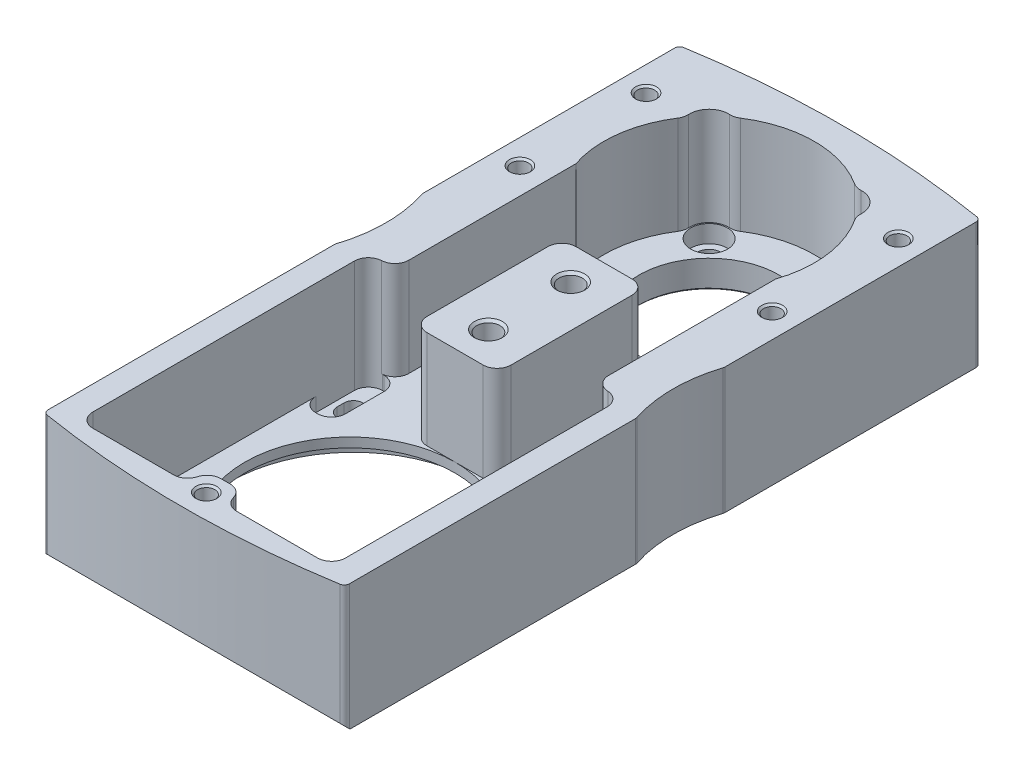
from build123d import *
from build123d.topology import SkipClean

# Parameters (mm, degrees)
BOSS_EXTRUDE1_DEPTH     = 36
CUT_EXTRUDE1_DEPTH      = 43
CUT_EXTRUDE1_DEPTH_BACK = 43
CUT_EXTRUDE2_DEPTH      = 32
CUT_EXTRUDE3_DEPTH      = 32
CUT_EXTRUDE4_DEPTH      = 32
CUT_EXTRUDE5_DEPTH      = 32
CUT_EXTRUDE6_DEPTH      = 36
CUT_EXTRUDE7_DEPTH      = 36
CUT_EXTRUDE8_DEPTH      = 36
CUT_EXTRUDE9_DEPTH      = 36
CUT_EXTRUDE10_DEPTH     = 5.3
CUT_EXTRUDE11_DEPTH     = 28
SKETCH25_W              = 30
SKETCH25_H              = 20
CUT_EXTRUDE12_DEPTH     = 28


with BuildPart() as part:
    # Sketch1 → Boss-Extrude1 (new body)
    with BuildSketch(Plane(origin=(0, 0, 0), x_dir=(1, 0, 0), z_dir=(0, 1, 0))):
        with BuildLine():
            Line((-43, 86.522077939), (-43, 4.879475348))
            ThreePointArc((-43, 4.879475348), (-42.64324868, 3.90840251), (-41.742690058, 3.399238362))
            ThreePointArc((-41.742690058, 3.399238362), (0, 0), (41.742690058, 3.399238362))
            ThreePointArc((41.742690058, 3.399238362), (42.64324868, 3.90840251), (43, 4.879475348))
            Line((43, 4.879475348), (43, 86.522077939))
            ThreePointArc((43, 86.522077939), (42.98181751, 86.754923096), (42.927710843, 86.982123314))
            ThreePointArc((42.927710843, 86.982123314), (41, 99.25), (42.927710843, 111.517876686))
            ThreePointArc((42.927710843, 111.517876686), (42.98181751, 111.745076904), (43, 111.977922061))
            Line((43, 111.977922061), (43, 183.620524652))
            ThreePointArc((43, 183.620524652), (42.64324868, 184.59159749), (41.742690058, 185.100761638))
            ThreePointArc((41.742690058, 185.100761638), (0, 188.5), (-41.742690058, 185.100761638))
            ThreePointArc((-41.742690058, 185.100761638), (-42.64324868, 184.59159749), (-43, 183.620524652))
            Line((-43, 183.620524652), (-43, 111.977922061))
            ThreePointArc((-43, 111.977922061), (-42.98181751, 111.745076904), (-42.927710843, 111.517876686))
            ThreePointArc((-42.927710843, 111.517876686), (-41, 99.25), (-42.927710843, 86.982123314))
            ThreePointArc((-42.927710843, 86.982123314), (-42.98181751, 86.754923096), (-43, 86.522077939))
        make_face()
    extrude(amount=BOSS_EXTRUDE1_DEPTH)

    # Sketch2 → Cut-Extrude1 (cut, two sides: drawn at the far end of the back side and taken through both)
    with BuildSketch(Plane(origin=(0, 0, 0), x_dir=(0, 0, -1), z_dir=(1, 0, 0)).offset(-CUT_EXTRUDE1_DEPTH_BACK)):
        Polygon((0, 5), (0, 0), (5, 0), align=None)
    extrude(amount=CUT_EXTRUDE1_DEPTH + CUT_EXTRUDE1_DEPTH_BACK, mode=Mode.SUBTRACT)

    # Sketch4 → Cut-Revolve1 (revolve, cut)
    with BuildSketch(Plane(origin=(0, 0, 0), x_dir=(0, 0, -1), z_dir=(1, 0, 0))):
        Polygon((111, 36), (115, 36), (114.3235, 35.3235), (114.3235, 6), (111, 4.08117638), align=None)
    revolve(axis=Axis((0, 4.08117638, -111), (0, 1, 0)), mode=Mode.SUBTRACT)

    # Sketch5 → Cut-Revolve2 (revolve, cut)
    with BuildSketch(Plane(origin=(0, 0, 0), x_dir=(0, 0, -1), z_dir=(1, 0, 0))):
        Polygon((87.5, 36), (91.5, 36), (90.8235, 35.3235), (90.8235, 6), (87.5, 4.08117638), align=None)
    revolve(axis=Axis((0, 4.08117638, -87.5), (0, 1, 0)), mode=Mode.SUBTRACT)

    # Sketch6 → Cut-Revolve3 (revolve, cut)
    with BuildSketch(Plane(origin=(-36, 0, 0), x_dir=(0, 0, -1), z_dir=(1, 0, 0))):
        Polygon((168.5, 36), (171.5, 36), (170.9585, 35.4585), (170.9585, 14), (168.5, 12.580584363), align=None)
    revolve(axis=Axis((-36, 12.580584363, -168.5), (0, 1, 0)), mode=Mode.SUBTRACT)

    # Sketch7 → Cut-Revolve4 (revolve, cut)
    with BuildSketch(Plane(origin=(-36, 0, 0), x_dir=(0, 0, -1), z_dir=(1, 0, 0))):
        Polygon((132.5, 36), (135.5, 36), (134.9585, 35.4585), (134.9585, 14), (132.5, 12.580584363), align=None)
    revolve(axis=Axis((-36, 12.580584363, -132.5), (0, 1, 0)), mode=Mode.SUBTRACT)

    # Sketch8 → Cut-Revolve5 (revolve, cut)
    with BuildSketch(Plane(origin=(36, 0, 0), x_dir=(0, 0, -1), z_dir=(1, 0, 0))):
        Polygon((168.5, 36), (171.5, 36), (170.9585, 35.4585), (170.9585, 14), (168.5, 12.580584363), align=None)
    revolve(axis=Axis((36, 12.580584363, -168.5), (0, 1, 0)), mode=Mode.SUBTRACT)

    # Sketch9 → Cut-Revolve6 (revolve, cut)
    with BuildSketch(Plane(origin=(36, 0, 0), x_dir=(0, 0, -1), z_dir=(1, 0, 0))):
        Polygon((132.5, 36), (135.5, 36), (134.9585, 35.4585), (134.9585, 14), (132.5, 12.580584363), align=None)
    revolve(axis=Axis((36, 12.580584363, -132.5), (0, 1, 0)), mode=Mode.SUBTRACT)

    # Sketch10 → Cut-Revolve7 (revolve, cut)
    with BuildSketch(Plane(origin=(0, 0, 0), x_dir=(0, 0, -1), z_dir=(1, 0, 0))):
        Polygon((7, 36), (10, 36), (9.4585, 35.4585), (9.4585, 14), (7, 12.580584363), align=None)
    revolve(axis=Axis((0, 12.580584363, -7), (0, 1, 0)), mode=Mode.SUBTRACT)

    # Sketch11 → Cut-Revolve8 (revolve, cut)
    with BuildSketch(Plane(origin=(0, 0, 0), x_dir=(0, 0, -1), z_dir=(1, 0, 0))):
        Polygon((150.5, 36), (170.5, 36), (170.5, 0.6), (171.1, 0), (150.5, 0), align=None)
    revolve(axis=Axis((0, 0, -150.5), (0, 1, 0)), mode=Mode.SUBTRACT)

    # Sketch12 → Cut-Revolve9 (revolve, cut)
    with BuildSketch(Plane(origin=(19, 0, 0), x_dir=(0, 0, -1), z_dir=(1, 0, 0))):
        Polygon((131.5, 36), (136.75, 36), (136.75, 3), (134.8, 3), (134.8, 0), (131.5, 0), align=None)
    revolve(axis=Axis((19, 0, -131.5), (0, 1, 0)), mode=Mode.SUBTRACT)

    # Sketch13 → Cut-Revolve10 (revolve, cut)
    with BuildSketch(Plane(origin=(19, 0, 0), x_dir=(0, 0, -1), z_dir=(1, 0, 0))):
        Polygon((169.5, 36), (174.75, 36), (174.75, 3), (172.8, 3), (172.8, 0), (169.5, 0), align=None)
    revolve(axis=Axis((19, 0, -169.5), (0, 1, 0)), mode=Mode.SUBTRACT)

    # Sketch14 → Cut-Revolve11 (revolve, cut)
    with BuildSketch(Plane(origin=(-19, 0, 0), x_dir=(0, 0, -1), z_dir=(1, 0, 0))):
        Polygon((131.5, 36), (136.75, 36), (136.75, 3), (134.8, 3), (134.8, 0), (131.5, 0), align=None)
    revolve(axis=Axis((-19, 0, -131.5), (0, 1, 0)), mode=Mode.SUBTRACT)

    # Sketch15 → Cut-Revolve12 (revolve, cut)
    with BuildSketch(Plane(origin=(-19, 0, 0), x_dir=(0, 0, -1), z_dir=(1, 0, 0))):
        Polygon((169.5, 36), (174.75, 36), (174.75, 3), (172.8, 3), (172.8, 0), (169.5, 0), align=None)
    revolve(axis=Axis((-19, 0, -169.5), (0, 1, 0)), mode=Mode.SUBTRACT)

    # Sketch16 → Cut-Extrude2 (cut)
    with BuildSketch(Plane(origin=(0, 36, 0), x_dir=(1, 0, 0), z_dir=(0, 1, 0))):
        with BuildLine():
            Line((31.569805153, 6.680194847), (32.069805153, 6.680194847))
            ThreePointArc((32.069805153, 6.680194847), (34.898232278, 7.851767722), (36.069805153, 10.680194847))
            Line((36.069805153, 10.680194847), (36.069805153, 21.680194847))
            ThreePointArc((36.069805153, 21.680194847), (34.898232278, 24.508621971), (32.069805153, 25.680194847))
            Line((32.069805153, 25.680194847), (31.569805153, 25.680194847))
            ThreePointArc((31.569805153, 25.680194847), (28.741378029, 24.508621971), (27.569805153, 21.680194847))
            Line((27.569805153, 21.680194847), (27.569805153, 10.680194847))
            ThreePointArc((27.569805153, 10.680194847), (28.741378029, 7.851767722), (31.569805153, 6.680194847))
        make_face()
    extrude(amount=-CUT_EXTRUDE2_DEPTH, mode=Mode.SUBTRACT)

    # Sketch17 → Cut-Extrude3 (cut)
    with BuildSketch(Plane(origin=(0, 36, 0), x_dir=(1, 0, 0), z_dir=(0, 1, 0))):
        with BuildLine():
            Line((31.569805153, 70.319805153), (32.069805153, 70.319805153))
            ThreePointArc((32.069805153, 70.319805153), (34.898232278, 71.491378029), (36.069805153, 74.319805153))
            Line((36.069805153, 74.319805153), (36.069805153, 85.319805153))
            ThreePointArc((36.069805153, 85.319805153), (34.898232278, 88.148232278), (32.069805153, 89.319805153))
            Line((32.069805153, 89.319805153), (31.569805153, 89.319805153))
            ThreePointArc((31.569805153, 89.319805153), (28.741378029, 88.148232278), (27.569805153, 85.319805153))
            Line((27.569805153, 85.319805153), (27.569805153, 74.319805153))
            ThreePointArc((27.569805153, 74.319805153), (28.741378029, 71.491378029), (31.569805153, 70.319805153))
        make_face()
    extrude(amount=-CUT_EXTRUDE3_DEPTH, mode=Mode.SUBTRACT)

    # Sketch18 → Cut-Extrude4 (cut)
    with BuildSketch(Plane(origin=(0, 36, 0), x_dir=(1, 0, 0), z_dir=(0, 1, 0))):
        with BuildLine():
            Line((-32.069805153, 70.319805153), (-31.569805153, 70.319805153))
            ThreePointArc((-31.569805153, 70.319805153), (-28.741378029, 71.491378029), (-27.569805153, 74.319805153))
            Line((-27.569805153, 74.319805153), (-27.569805153, 85.319805153))
            ThreePointArc((-27.569805153, 85.319805153), (-28.741378029, 88.148232278), (-31.569805153, 89.319805153))
            Line((-31.569805153, 89.319805153), (-32.069805153, 89.319805153))
            ThreePointArc((-32.069805153, 89.319805153), (-34.898232278, 88.148232278), (-36.069805153, 85.319805153))
            Line((-36.069805153, 85.319805153), (-36.069805153, 74.319805153))
            ThreePointArc((-36.069805153, 74.319805153), (-34.898232278, 71.491378029), (-32.069805153, 70.319805153))
        make_face()
    extrude(amount=-CUT_EXTRUDE4_DEPTH, mode=Mode.SUBTRACT)

    # Sketch19 → Cut-Extrude5 (cut)
    with BuildSketch(Plane(origin=(0, 36, 0), x_dir=(1, 0, 0), z_dir=(0, 1, 0))):
        with BuildLine():
            Line((-32.069805153, 6.680194847), (-31.569805153, 6.680194847))
            ThreePointArc((-31.569805153, 6.680194847), (-28.741378029, 7.851767722), (-27.569805153, 10.680194847))
            Line((-27.569805153, 10.680194847), (-27.569805153, 21.680194847))
            ThreePointArc((-27.569805153, 21.680194847), (-28.741378029, 24.508621971), (-31.569805153, 25.680194847))
            Line((-31.569805153, 25.680194847), (-32.069805153, 25.680194847))
            ThreePointArc((-32.069805153, 25.680194847), (-34.898232278, 24.508621971), (-36.069805153, 21.680194847))
            Line((-36.069805153, 21.680194847), (-36.069805153, 10.680194847))
            ThreePointArc((-36.069805153, 10.680194847), (-34.898232278, 7.851767722), (-32.069805153, 6.680194847))
        make_face()
    extrude(amount=-CUT_EXTRUDE5_DEPTH, mode=Mode.SUBTRACT)

    # Sketch20 → Cut-Extrude6 (cut)
    with BuildSketch(Plane(origin=(0, 36, 0), x_dir=(1, 0, 0), z_dir=(0, 1, 0))):
        with BuildLine():
            Line((34.469805153, 15.180194847), (34.469805153, 17.180194847))
            ThreePointArc((34.469805153, 17.180194847), (31.819805153, 19.830194847), (29.169805153, 17.180194847))
            Line((29.169805153, 17.180194847), (29.169805153, 15.180194847))
            ThreePointArc((29.169805153, 15.180194847), (31.819805153, 12.530194847), (34.469805153, 15.180194847))
        make_face()
    extrude(amount=-CUT_EXTRUDE6_DEPTH, mode=Mode.SUBTRACT)

    # Sketch21 → Cut-Extrude7 (cut)
    with BuildSketch(Plane(origin=(0, 36, 0), x_dir=(1, 0, 0), z_dir=(0, 1, 0))):
        with BuildLine():
            Line((34.469805153, 78.819805153), (34.469805153, 80.819805153))
            ThreePointArc((34.469805153, 80.819805153), (31.819805153, 83.469805153), (29.169805153, 80.819805153))
            Line((29.169805153, 80.819805153), (29.169805153, 78.819805153))
            ThreePointArc((29.169805153, 78.819805153), (31.819805153, 76.169805153), (34.469805153, 78.819805153))
        make_face()
    extrude(amount=-CUT_EXTRUDE7_DEPTH, mode=Mode.SUBTRACT)

    # Sketch22 → Cut-Extrude8 (cut)
    with BuildSketch(Plane(origin=(0, 36, 0), x_dir=(1, 0, 0), z_dir=(0, 1, 0))):
        with BuildLine():
            Line((-29.169805153, 78.819805153), (-29.169805153, 80.819805153))
            ThreePointArc((-29.169805153, 80.819805153), (-31.819805153, 83.469805153), (-34.469805153, 80.819805153))
            Line((-34.469805153, 80.819805153), (-34.469805153, 78.819805153))
            ThreePointArc((-34.469805153, 78.819805153), (-31.819805153, 76.169805153), (-29.169805153, 78.819805153))
        make_face()
    extrude(amount=-CUT_EXTRUDE8_DEPTH, mode=Mode.SUBTRACT)

    # Sketch23 → Cut-Extrude9 (cut)
    with BuildSketch(Plane(origin=(0, 36, 0), x_dir=(1, 0, 0), z_dir=(0, 1, 0))):
        with BuildLine():
            Line((-29.169805153, 15.180194847), (-29.169805153, 17.180194847))
            ThreePointArc((-29.169805153, 17.180194847), (-31.819805153, 19.830194847), (-34.469805153, 17.180194847))
            Line((-34.469805153, 17.180194847), (-34.469805153, 15.180194847))
            ThreePointArc((-34.469805153, 15.180194847), (-31.819805153, 12.530194847), (-29.169805153, 15.180194847))
        make_face()
    extrude(amount=-CUT_EXTRUDE9_DEPTH, mode=Mode.SUBTRACT)

    # Sketch24 → Cut-Extrude10 (cut)
    with BuildSketch(Plane(origin=(0, 0, 0), x_dir=(1, 0, 0), z_dir=(0, 1, 0))):
        with BuildLine():
            Line((35.25, 47), (35.25, 49))
            ThreePointArc((35.25, 49), (0, 84.25), (-35.25, 49))
            Line((-35.25, 49), (-35.25, 47))
            ThreePointArc((-35.25, 47), (0, 11.75), (35.25, 47))
        make_face()
    extrude(amount=CUT_EXTRUDE10_DEPTH, mode=Mode.SUBTRACT)

    # Sketch3 → Cut-Extrude11 (cut)
    with BuildSketch(Plane(origin=(0, 36, 0), x_dir=(1, 0, 0), z_dir=(0, 1, 0))):
        with BuildLine():
            Line((28.5, 57.526410657), (28.5, 141.132503002))
            ThreePointArc((28.5, 141.132503002), (0, 180.5), (-28.5, 141.132503002))
            Line((-28.5, 141.132503002), (-28.5, 57.526410657))
            ThreePointArc((-28.5, 57.526410657), (0, 17.95), (28.5, 57.526410657))
        make_face()
        with BuildLine():
            Line((-12, 116.5), (-12, 82))
            ThreePointArc((-12, 82), (-10.828427125, 79.171572875), (-8, 78))
            Line((-8, 78), (8, 78))
            ThreePointArc((8, 78), (10.828427125, 79.171572875), (12, 82))
            Line((12, 82), (12, 116.5))
            ThreePointArc((12, 116.5), (10.828427125, 119.328427125), (8, 120.5))
            Line((8, 120.5), (-8, 120.5))
            ThreePointArc((-8, 120.5), (-10.828427125, 119.328427125), (-12, 116.5))
        make_face(mode=Mode.SUBTRACT)
    extrude(amount=-CUT_EXTRUDE11_DEPTH, mode=Mode.SUBTRACT)

    # Sketch25 → Cut-Revolve13 (revolve, cut)
    with BuildSketch(Plane(origin=(0, 0, 0), x_dir=(0, 0, -1), z_dir=(1, 0, 0))):
        with Locations((63, 10)):
            Rectangle(SKETCH25_W, SKETCH25_H)
    revolve(axis=Axis((0, 0, -48), (0, 1, 0)), mode=Mode.SUBTRACT)

    # Sketch26 → Cut-Extrude12 (cut)
    with SkipClean():  # the faces are left unmerged after this step: merging them gives an invalid solid
        with BuildSketch(Plane(origin=(0, 36, 0), x_dir=(1, 0, 0), z_dir=(0, 1, 0))):
            with BuildLine():
                Line((-36.069805153, 85.319805153), (-36.069805153, 10.680194847))
                ThreePointArc((-36.069805153, 10.680194847), (-34.898232278, 7.851767722), (-32.069805153, 6.680194847))
                Line((-32.069805153, 6.680194847), (-9, 6.680194847))
                ThreePointArc((-9, 6.680194847), (-6.587572767, 7.489553086), (-5.151404463, 9.590097423))
                ThreePointArc((-5.151404463, 9.590097423), (-3.715236159, 11.690641761), (-1.302808926, 12.5))
                Line((-1.302808926, 12.5), (1.302808926, 12.5))
                ThreePointArc((1.302808926, 12.5), (3.715236159, 11.690641761), (5.151404463, 9.590097423))
                ThreePointArc((5.151404463, 9.590097423), (6.587572767, 7.489553086), (9, 6.680194847))
                Line((9, 6.680194847), (32.069805153, 6.680194847))
                ThreePointArc((32.069805153, 6.680194847), (34.898232278, 7.851767722), (36.069805153, 10.680194847))
                Line((36.069805153, 10.680194847), (36.069805153, 85.319805153))
                ThreePointArc((36.069805153, 85.319805153), (34.973284936, 88.071133043), (32.284902577, 89.314017604))
                ThreePointArc((32.284902577, 89.314017604), (29.596520218, 90.556902165), (28.5, 93.308230054))
                Line((28.5, 93.308230054), (28.5, 140.973589343))
                ThreePointArc((28.5, 140.973589343), (29.812257553, 154.272505746), (25.228664015, 166.825348757))
                ThreePointArc((25.228664015, 166.825348757), (24.722390611, 167.9661352), (24.592351825, 169.207423395))
                ThreePointArc((24.592351825, 169.207423395), (22.959797975, 173.459797975), (18.707423395, 175.092351825))
                ThreePointArc((18.707423395, 175.092351825), (17.4661352, 175.222390611), (16.325348757, 175.728664015))
                ThreePointArc((16.325348757, 175.728664015), (0, 180.55), (-16.325348757, 175.728664015))
                ThreePointArc((-16.325348757, 175.728664015), (-17.4661352, 175.222390611), (-18.707423395, 175.092351825))
                ThreePointArc((-18.707423395, 175.092351825), (-22.959797975, 173.459797975), (-24.592351825, 169.207423395))
                ThreePointArc((-24.592351825, 169.207423395), (-24.722390611, 167.9661352), (-25.228664015, 166.825348757))
                ThreePointArc((-25.228664015, 166.825348757), (-29.812257553, 154.272505746), (-28.5, 140.973589343))
                Line((-28.5, 140.973589343), (-28.5, 93.308230054))
                ThreePointArc((-28.5, 93.308230054), (-29.596520218, 90.556902165), (-32.284902577, 89.314017604))
                ThreePointArc((-32.284902577, 89.314017604), (-34.973284936, 88.071133043), (-36.069805153, 85.319805153))
            make_face()
            with BuildLine():
                Line((-12, 116.5), (-12, 82))
                ThreePointArc((-12, 82), (-10.828427125, 79.171572875), (-8, 78))
                Line((-8, 78), (8, 78))
                ThreePointArc((8, 78), (10.828427125, 79.171572875), (12, 82))
                Line((12, 82), (12, 116.5))
                ThreePointArc((12, 116.5), (10.828427125, 119.328427125), (8, 120.5))
                Line((8, 120.5), (-8, 120.5))
                ThreePointArc((-8, 120.5), (-10.828427125, 119.328427125), (-12, 116.5))
            make_face(mode=Mode.SUBTRACT)
        extrude(amount=-CUT_EXTRUDE12_DEPTH, mode=Mode.SUBTRACT)


solid = part.part
